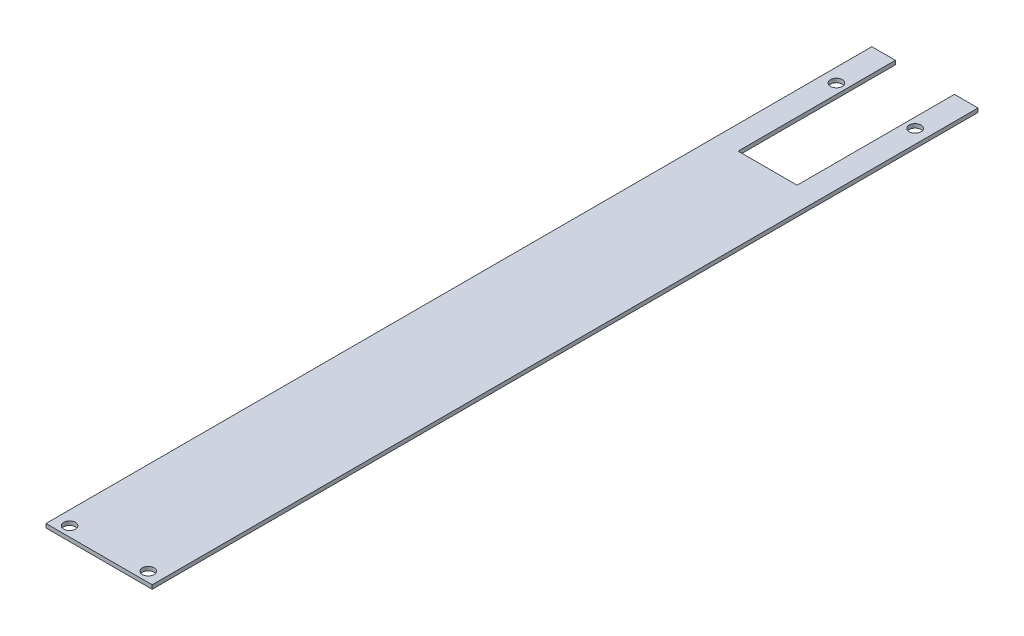
from build123d import *

# Parameters (mm, degrees)
SKETCH1_W           = 54
SKETCH1_H           = 420
BOSS_EXTRUDE1_DEPTH = 2
CUT_EXTRUDE1_REACH  = 4
SKETCH2_W           = 30
SKETCH2_H           = 80
CUT_EXTRUDE2_REACH  = 4
SKETCH3_R           = 3


with BuildPart() as part:
    # Sketch1 → Boss-Extrude1 (new body)
    with BuildSketch(Plane(origin=(0, 100, 0), x_dir=(-1, 0, 0), z_dir=(0, 1, 0))):
        with Locations((1.051745534, 184.692172039)):
            Rectangle(SKETCH1_W, SKETCH1_H)
    extrude(amount=BOSS_EXTRUDE1_DEPTH)

    # Sketch2 → Cut-Extrude1 (cut, up to next)
    with BuildSketch(Plane(origin=(0, 102, 0), x_dir=(-1, 0, 0), z_dir=(0, 1, 0)), mode=Mode.PRIVATE) as cut_extrude1_sk1:
        with Locations((1.051745534, 14.692172039)):
            Rectangle(SKETCH2_W, SKETCH2_H)
    cut_extrude1_tool1 = extrude(cut_extrude1_sk1.sketch, amount=-CUT_EXTRUDE1_REACH, mode=Mode.PRIVATE) & part.part
    add(cut_extrude1_tool1.solids().sort_by_distance((-1.051746, 102, 14.692172))[0], mode=Mode.SUBTRACT)

    # Sketch3 → Cut-Extrude2 (cut, up to next)
    with BuildSketch(Plane(origin=(0, 102, 0), x_dir=(-1, 0, 0), z_dir=(0, 1, 0)), mode=Mode.PRIVATE) as cut_extrude2_sk1:
        with Locations((-18.948254466, -0.307827961)):
            Circle(SKETCH3_R)
    cut_extrude2_tool1 = extrude(cut_extrude2_sk1.sketch, amount=-CUT_EXTRUDE2_REACH, mode=Mode.PRIVATE) & part.part
    add(cut_extrude2_tool1.solids().sort_by_distance((18.948254, 102, -0.307828))[0], mode=Mode.SUBTRACT)
    # Sketch3 → Cut-Extrude2 (cut, up to next)
    with BuildSketch(Plane(origin=(0, 102, 0), x_dir=(-1, 0, 0), z_dir=(0, 1, 0)), mode=Mode.PRIVATE) as cut_extrude2_sk2:
        with Locations((21.051745534, -0.307827961)):
            Circle(SKETCH3_R)
    cut_extrude2_tool2 = extrude(cut_extrude2_sk2.sketch, amount=-CUT_EXTRUDE2_REACH, mode=Mode.PRIVATE) & part.part
    add(cut_extrude2_tool2.solids().sort_by_distance((-21.051746, 102, -0.307828))[0], mode=Mode.SUBTRACT)
    # Sketch3 → Cut-Extrude2 (cut, up to next)
    with BuildSketch(Plane(origin=(0, 102, 0), x_dir=(-1, 0, 0), z_dir=(0, 1, 0)), mode=Mode.PRIVATE) as cut_extrude2_sk3:
        with Locations((21.051745534, 389.692172039)):
            Circle(SKETCH3_R)
    cut_extrude2_tool3 = extrude(cut_extrude2_sk3.sketch, amount=-CUT_EXTRUDE2_REACH, mode=Mode.PRIVATE) & part.part
    add(cut_extrude2_tool3.solids().sort_by_distance((-21.051746, 102, 389.692172))[0], mode=Mode.SUBTRACT)
    # Sketch3 → Cut-Extrude2 (cut, up to next)
    with BuildSketch(Plane(origin=(0, 102, 0), x_dir=(-1, 0, 0), z_dir=(0, 1, 0)), mode=Mode.PRIVATE) as cut_extrude2_sk4:
        with Locations((-18.948254466, 389.692172039)):
            Circle(SKETCH3_R)
    cut_extrude2_tool4 = extrude(cut_extrude2_sk4.sketch, amount=-CUT_EXTRUDE2_REACH, mode=Mode.PRIVATE) & part.part
    add(cut_extrude2_tool4.solids().sort_by_distance((18.948254, 102, 389.692172))[0], mode=Mode.SUBTRACT)


solid = part.part
